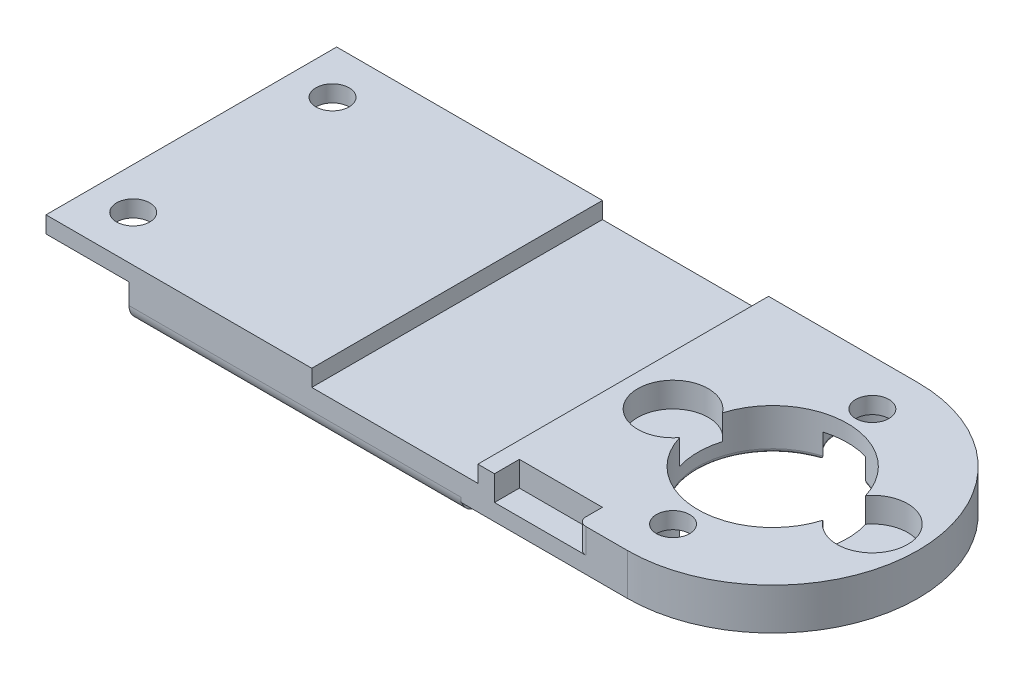
from build123d import *

# Parameters (mm, degrees)
SKETCH1_W               = 40
SKETCH1_H               = 35
BOSS_EXTRUDE1_DEPTH     = 8
CUT_EXTRUDE1_DEPTH      = 1
CUT_EXTRUDE1_DEPTH_BACK = 41
FILLET1_R               = 2
SKETCH6_R               = 2
BOSS_EXTRUDE2_DEPTH     = 5
CUT_EXTRUDE2_DEPTH      = 7.467619242
SKETCH6_7_R             = 4.25
CUT_EXTRUDE3_DEPTH      = 3
SKETCH7_W               = 10
SKETCH7_H               = 3
CUT_EXTRUDE4_DEPTH      = 3
FILLET2_R               = 1
SKETCH8_W               = 20
SKETCH8_H               = 2
CUT_EXTRUDE5_DEPTH      = 36
SKETCH10_R              = 4.25
SKETCH10_R_2            = 2
SKETCH10_R_3            = 9
CUT_EXTRUDE6_DEPTH      = 3
FILLET3_R               = 0.5
SKETCH5_W               = 35
SKETCH5_H               = 2
BOSS_EXTRUDE3_DEPTH     = 10
SKETCH12_R              = 2
CUT_EXTRUDE7_DEPTH      = 7.467619242


with BuildPart() as part:
    # Sketch1 → Boss-Extrude1 (new body)
    with BuildSketch(Plane(origin=(0, 0, 0), x_dir=(1, 0, 0), z_dir=(0, 1, 0))):
        Rectangle(SKETCH1_W, SKETCH1_H)
    extrude(amount=-BOSS_EXTRUDE1_DEPTH)

    # Sketch2 → Cut-Extrude1 (cut, two sides)
    with BuildSketch(Plane(origin=(20, 0, 0), x_dir=(0, 0, -1), z_dir=(1, 0, 0))) as cut_extrude1_sk:
        Polygon((-12.5, -5), (-17.5, -8), (0, -8), (0, -5), align=None)
        Polygon((0, -5), (0, -8), (17.5, -8), (12.5, -5), align=None)
    extrude(amount=CUT_EXTRUDE1_DEPTH, mode=Mode.SUBTRACT)
    extrude(cut_extrude1_sk.sketch, amount=-CUT_EXTRUDE1_DEPTH_BACK, mode=Mode.SUBTRACT)

    # Fillet1
    fillet1_edges = [part.edges().sort_by_distance(p)[0] for p in [
        (0, -8, -17.5),
        (0, -5, 12.5),
        (0, -5, -12.5),
        (0, -8, 17.5),
    ]]
    fillet(fillet1_edges, radius=FILLET1_R)

    # Sketch6 → Boss-Extrude2 (add)
    with BuildSketch(Plane(origin=(0, 0, 0), x_dir=(1, 0, 0), z_dir=(0, 1, 0))):
        with BuildLine():
            Line((20, 17.5), (20, -17.5))
            Line((20, -17.5), (40, -17.5))
            ThreePointArc((40, -17.5), (57.5, 0), (40, 17.5))
            Line((40, 17.5), (20, 17.5))
        make_face()
        with Locations((40, -12)):
            Circle(SKETCH6_R, mode=Mode.SUBTRACT)
        with BuildLine():
            ThreePointArc((37.420408929, -8.622395833), (40, -7.75), (42.579591071, -8.622395833))
            ThreePointArc((42.579591071, -8.622395833), (40, -9), (37.420408929, -8.622395833))
        make_face(mode=Mode.SUBTRACT)
        with BuildLine():
            ThreePointArc((31.377604167, -2.579591071), (31, 0), (31.377604167, 2.579591071))
            ThreePointArc((31.377604167, 2.579591071), (32.025997871, 1.361558352), (32.25, 0))
            ThreePointArc((32.25, 0), (32.025997871, -1.361558352), (31.377604167, -2.579591071))
        make_face(mode=Mode.SUBTRACT)
        with BuildLine():
            ThreePointArc((37.420408929, 8.622395833), (40, 9), (42.579591071, 8.622395833))
            ThreePointArc((42.579591071, 8.622395833), (40, 7.75), (37.420408929, 8.622395833))
        make_face(mode=Mode.SUBTRACT)
        with Locations((40, 12)):
            Circle(SKETCH6_R, mode=Mode.SUBTRACT)
        with BuildLine():
            ThreePointArc((48.622395833, -2.579591071), (47.75, 0), (48.622395833, 2.579591071))
            ThreePointArc((48.622395833, 2.579591071), (49, 0), (48.622395833, -2.579591071))
        make_face(mode=Mode.SUBTRACT)
    extrude(amount=-BOSS_EXTRUDE2_DEPTH)

    # Sketch6_6 → Cut-Extrude2 (cut, through all)
    with BuildSketch(Plane(origin=(0, 0, 0), x_dir=(1, 0, 0), z_dir=(0, 1, 0))):
        with BuildLine():
            ThreePointArc((37.420408929, 8.622395833), (33.636038969, 6.363961031), (31.377604167, 2.579591071))
            ThreePointArc((31.377604167, 2.579591071), (32.025997871, 1.361558352), (32.25, 0))
            ThreePointArc((32.25, 0), (32.025997871, -1.361558352), (31.377604167, -2.579591071))
            ThreePointArc((31.377604167, -2.579591071), (33.636038969, -6.363961031), (37.420408929, -8.622395833))
            ThreePointArc((37.420408929, -8.622395833), (40, -7.75), (42.579591071, -8.622395833))
            ThreePointArc((42.579591071, -8.622395833), (46.363961031, -6.363961031), (48.622395833, -2.579591071))
            ThreePointArc((48.622395833, -2.579591071), (47.75, 0), (48.622395833, 2.579591071))
            ThreePointArc((48.622395833, 2.579591071), (46.363961031, 6.363961031), (42.579591071, 8.622395833))
            ThreePointArc((42.579591071, 8.622395833), (40, 7.75), (37.420408929, 8.622395833))
        make_face()
    extrude(amount=-CUT_EXTRUDE2_DEPTH, mode=Mode.SUBTRACT)

    # Sketch6_7 → Cut-Extrude3 (cut)
    with BuildSketch(Plane(origin=(0, 0, 0), x_dir=(1, 0, 0), z_dir=(0, 1, 0))):
        with Locations((52, 0)):
            Circle(SKETCH6_7_R)
        with Locations((28, 0)):
            Circle(SKETCH6_7_R)
    extrude(amount=-CUT_EXTRUDE3_DEPTH, mode=Mode.SUBTRACT)

    # Sketch7 → Cut-Extrude4 (cut)
    with BuildSketch(Plane(origin=(0, 0, 0), x_dir=(1, 0, 0), z_dir=(0, 1, 0))):
        with Locations((29, -16)):
            Rectangle(SKETCH7_W, SKETCH7_H)
    extrude(amount=-CUT_EXTRUDE4_DEPTH, mode=Mode.SUBTRACT)

    # Fillet2
    fillet2_edges = [part.edges().sort_by_distance(p)[0] for p in [
        (34, -1.5, 17.5),
    ]]
    fillet(fillet2_edges, radius=FILLET2_R)

    # Sketch8 → Cut-Extrude5 (cut, through all)
    with BuildSketch(Plane.XY.offset(17.5)):
        with Locations((12, -1)):
            Rectangle(SKETCH8_W, SKETCH8_H)
    extrude(amount=-CUT_EXTRUDE5_DEPTH, mode=Mode.SUBTRACT)

    # Sketch10 → Cut-Extrude6 (cut)
    with BuildSketch(Plane.XZ.offset(5)):
        with Locations((40, -12)):
            Circle(SKETCH10_R)
        with Locations((40, -12)):
            Circle(SKETCH10_R_2, mode=Mode.SUBTRACT)
        with Locations((40, 0)):
            Circle(SKETCH10_R_3)
        with Locations((40, 12)):
            Circle(SKETCH10_R)
        with Locations((40, 12)):
            Circle(SKETCH10_R_2, mode=Mode.SUBTRACT)
        with Locations((40, 0)):
            Circle(SKETCH10_R_3)
    extrude(amount=-CUT_EXTRUDE6_DEPTH, mode=Mode.SUBTRACT)

    # Fillet3
    fillet3_edges = [part.edges().sort_by_distance(p)[0] for p in [
        (49, -5, 0),
        (40, -5, -16.25),
        (40, -5, 16.25),
        (31, -5, 0),
    ]]
    fillet(fillet3_edges, radius=FILLET3_R)

    # Sketch5 → Boss-Extrude3 (add)
    with BuildSketch(Plane.ZY.offset(20)):
        with Locations((0, -1)):
            Rectangle(SKETCH5_W, SKETCH5_H)
    extrude(amount=BOSS_EXTRUDE3_DEPTH)

    # Sketch12 → Cut-Extrude7 (cut, through all)
    with BuildSketch(Plane(origin=(0, 0, 0), x_dir=(1, 0, 0), z_dir=(0, 1, 0))):
        with Locations((-25, 12)):
            Circle(SKETCH12_R)
        with Locations((-25, -12)):
            Circle(SKETCH12_R)
    extrude(amount=-CUT_EXTRUDE7_DEPTH, mode=Mode.SUBTRACT)


solid = part.part
